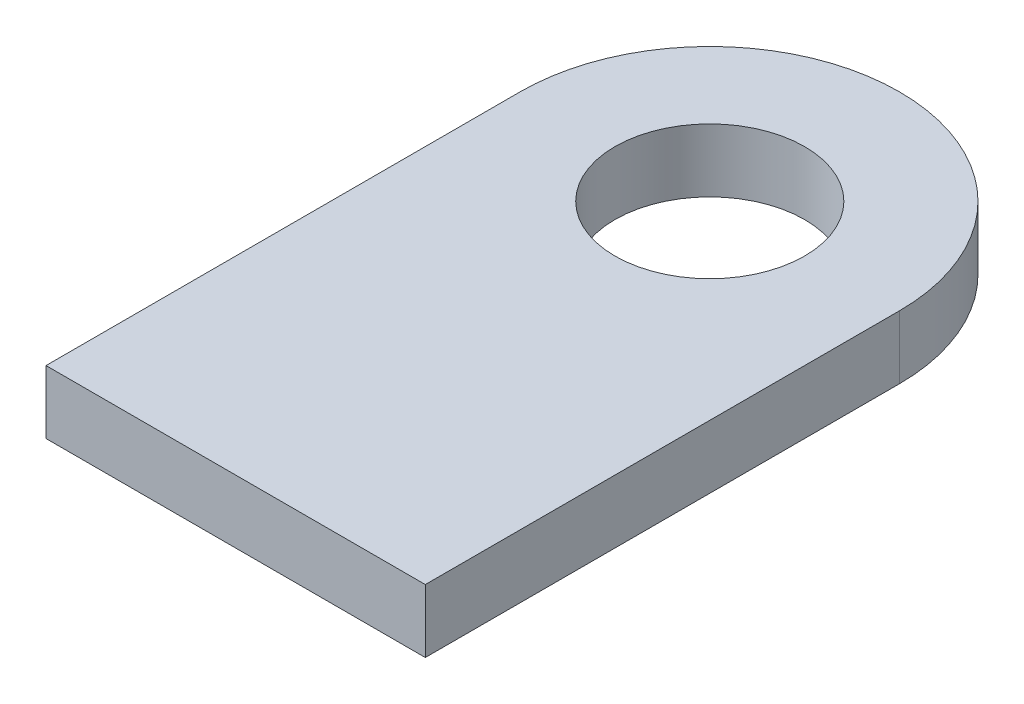
from build123d import *

# Parameters (mm, degrees)
DODANIE_WYCI_GNI_CIE1_DEPTH = 2
OTW_R1_D                    = 6
OTW_R1_DEPTH                = 2


with BuildPart() as part:
    # Szkic1 → Dodanie-wyciągnięcie1 (new body)
    with BuildSketch(Plane(origin=(0, 0, 0), x_dir=(1, 0, 0), z_dir=(0, 1, 0))):
        with BuildLine():
            Line((-6, 0), (-6, -15))
            Line((-6, -15), (6, -15))
            Line((6, -15), (6, 0))
            ThreePointArc((6, 0), (0, 6), (-6, 0))
        make_face()
    extrude(amount=DODANIE_WYCI_GNI_CIE1_DEPTH)

    # Otwór1
    with Locations(Plane(origin=(0, 2, 0), x_dir=(1, 0, 0), z_dir=(0, 1, 0))):
        with Locations((0, 0)):
            Hole(OTW_R1_D / 2, depth=OTW_R1_DEPTH)


solid = part.part
